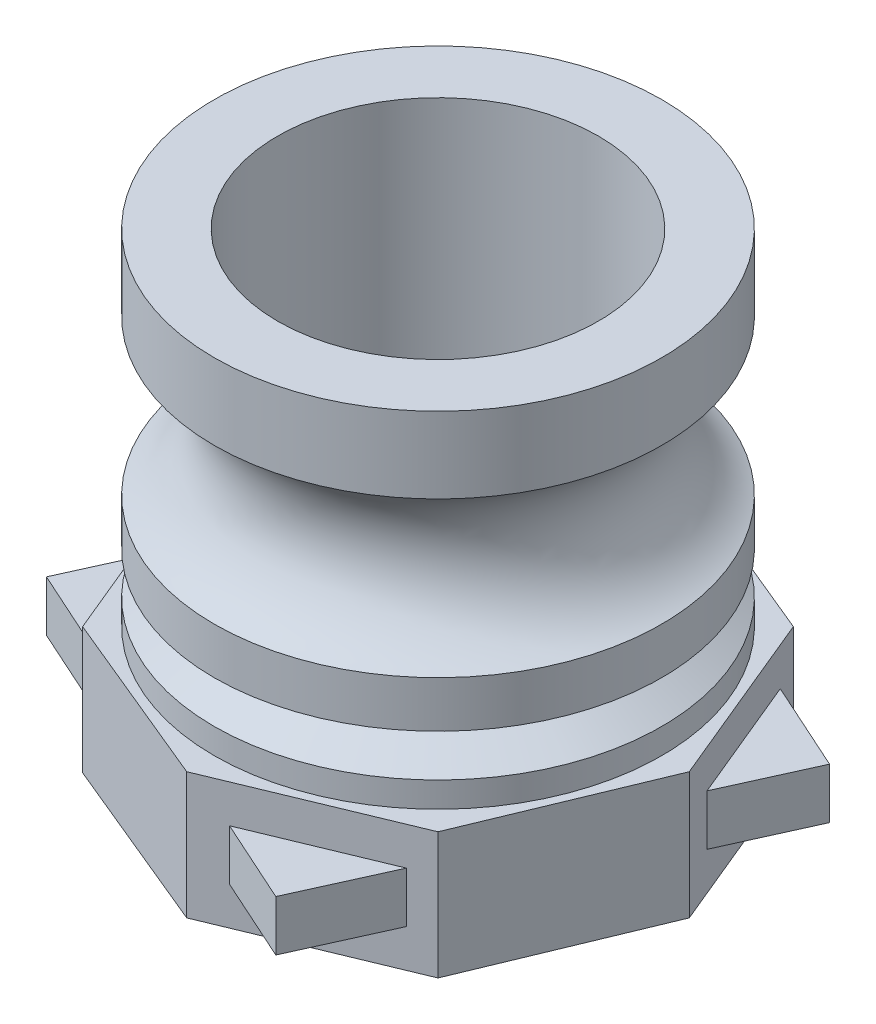
from build123d import *

# Parameters (mm, degrees)
SKETCH1_R           = 19
BOSS_EXTRUDE2_DEPTH = 15
SKETCH3_R           = 19
CUT_EXTRUDE1_DEPTH  = 56.83030278
BOSS_EXTRUDE3_DEPTH = 3
CIRPATTERN1_COUNT   = 4


with BuildPart() as part:
    # Sketch1 → Boss-Extrude2 (new body)
    with BuildSketch(Plane(origin=(0, 0, 0), x_dir=(1, 0, 0), z_dir=(0, 1, 0))):
        Polygon((21.04758878, 21.04758878), (0, 29.765785508), (-21.04758878, 21.04758878), (-29.765785508, 0), (-21.04758878, -21.04758878), (0, -29.765785508), (21.04758878, -21.04758878), (29.765785508, 0), align=None)
        Circle(SKETCH1_R, mode=Mode.SUBTRACT)
    extrude(amount=BOSS_EXTRUDE2_DEPTH)

    # Sketch2 → Revolve2 (revolve)
    with BuildSketch(Plane.XY):
        with BuildLine():
            Line((26.5, 46.83030278), (26.5, 55.83030278))
            Line((26.5, 55.83030278), (0, 55.83030278))
            Line((0, 55.83030278), (0, 15))
            Line((0, 15), (26.5, 15))
            Line((26.5, 15), (26.5, 28.5))
            ThreePointArc((26.5, 28.5), (20.5, 37.66515139), (26.5, 46.83030278))
        make_face()
    revolve(axis=Axis((0, 102.251774254, 0), (0, -1, 0)))

    # Sketch3 → Cut-Extrude1 (cut, through all)
    with BuildSketch(Plane(origin=(0, 55.83030278, 0), x_dir=(1, 0, 0), z_dir=(0, 1, 0))):
        Circle(SKETCH3_R)
    extrude(amount=-CUT_EXTRUDE1_DEPTH, mode=Mode.SUBTRACT)

    # Sketch4 → Boss-Extrude3 (add, symmetric)
    with BuildSketch(Plane(origin=(0, 7.5, 0), x_dir=(1, 0, 0), z_dir=(0, 1, 0))):
        Polygon((22.145562855, 18.396844877), (28.280721426, 3.585261849), (32.797723404, 13.585261849), align=None)
    boss_extrude3 = extrude(amount=BOSS_EXTRUDE3_DEPTH, both=True)

    # Sketch6 → Cut-Revolve1 (revolve, cut)
    with BuildSketch(Plane.XY):
        Polygon((26.5, 23), (22.169872981, 20.5), (26.5, 18), align=None)
    revolve(axis=Axis((0, -19.954319923, 0), (0, 1, 0)), mode=Mode.SUBTRACT)

    # CirPattern1: Boss-Extrude3 ×4 about axis
    cirpattern1_axis = Axis((0, 0, 0), (0, 1, 0))
    for i in range(1, CIRPATTERN1_COUNT):
        add(boss_extrude3.rotate(cirpattern1_axis, i * 360 / CIRPATTERN1_COUNT))


solid = part.part
